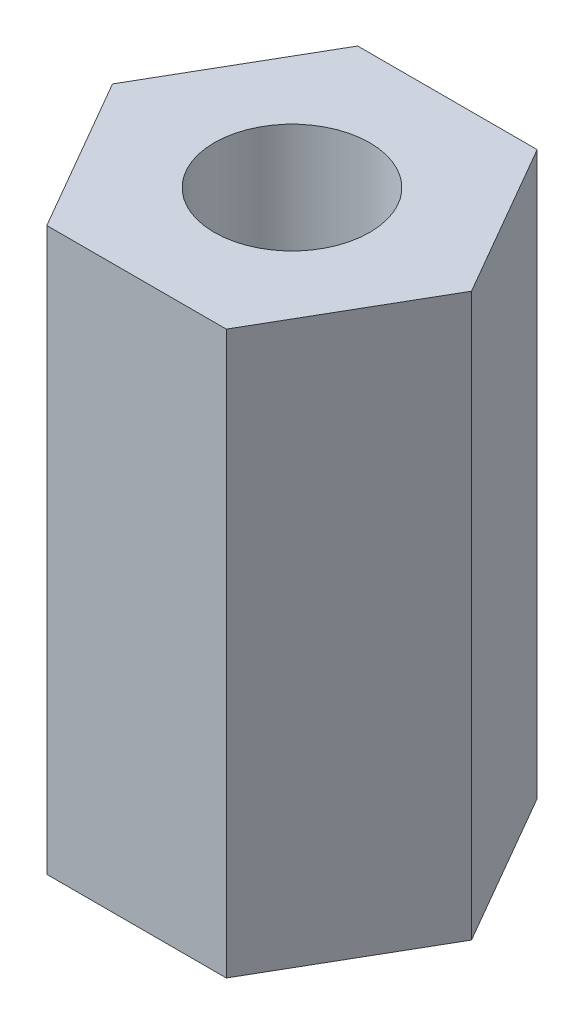
from build123d import *

# Parameters (mm, degrees)
SKETCH_1_R      = 1
EXTRUDE_1_DEPTH = 7.23


with BuildPart() as part:
    # 草图1 → 凸台-拉伸1 (new body)
    with BuildSketch(Plane(origin=(0, 0, 0), x_dir=(1, 0, 0), z_dir=(0, 1, 0))):
        Polygon((2.309401077, 0), (1.154700538, 2), (-1.154700538, 2), (-2.309401077, 0), (-1.154700538, -2), (1.154700538, -2), align=None)
        Circle(SKETCH_1_R, mode=Mode.SUBTRACT)
    extrude(amount=EXTRUDE_1_DEPTH)


solid = part.part
